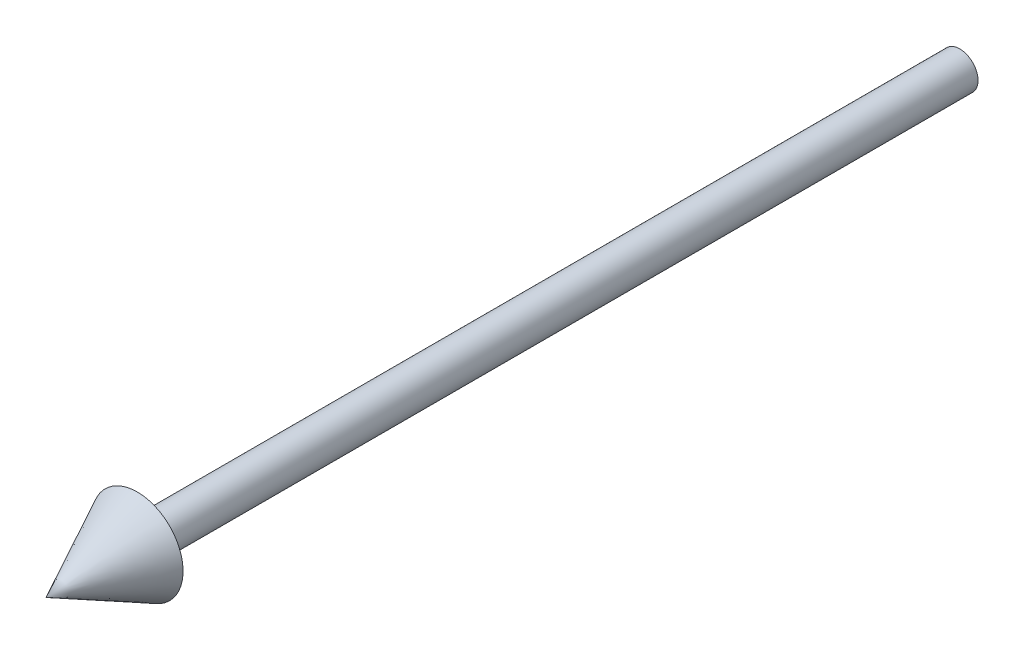
from build123d import *


with BuildPart() as part:
    # Sketch2 → Revolve1 (revolve)
    with BuildSketch(Plane(origin=(0, 0, 0), x_dir=(1, 0, 0), z_dir=(0, 1, 0))):
        Polygon((0, -100), (5, -90), (2, -90), (2, 0), (0, 0), align=None)
    revolve(axis=Axis((0, 0, -41.949952025), (0, 0, 1)))


solid = part.part
